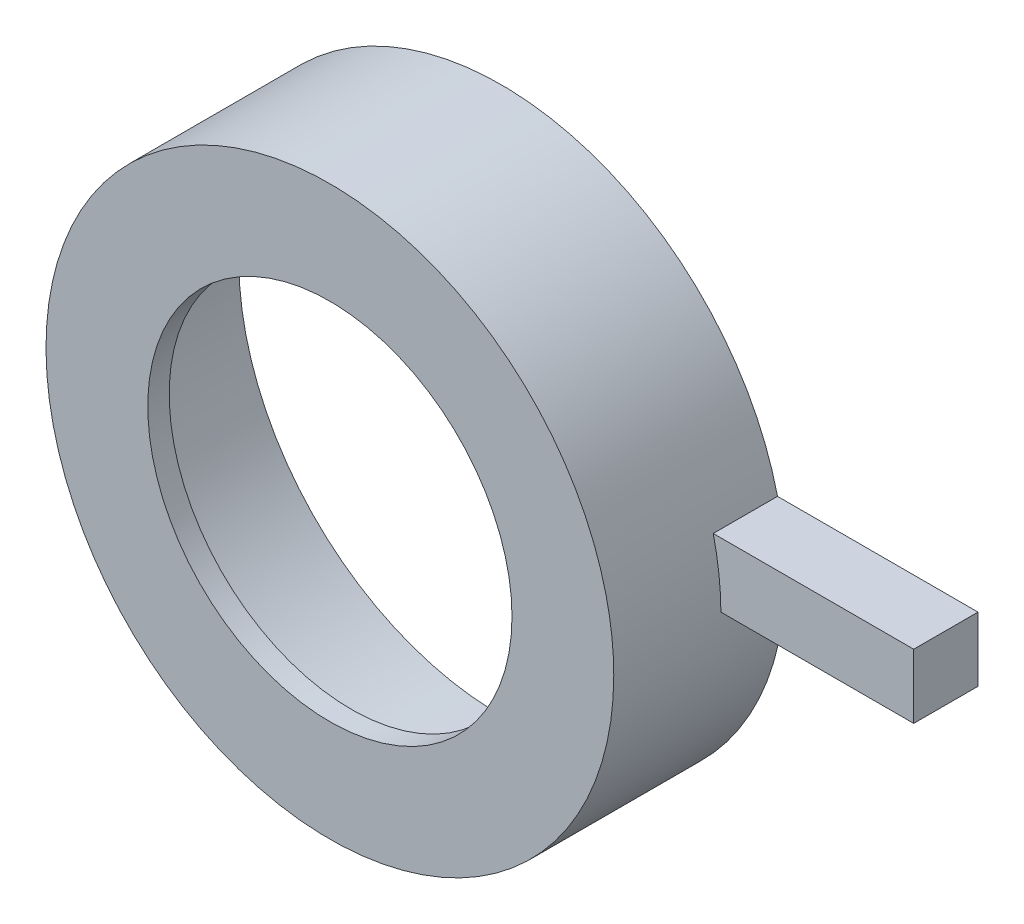
from build123d import *

# Parameters (mm, degrees)
SKETCH_1_R      = 13.25
SKETCH_1_R_2    = 12.25
EXTRUDE_1_DEPTH = 7
SKETCH_2_R      = 13.25
SKETCH_2_R_2    = 8.5
EXTRUDE_2_DEPTH = 1
SKETCH_3_W      = 10
SKETCH_3_H      = 3
EXTRUDE_3_DEPTH = 3


with BuildPart() as part:
    # ｽｹｯﾁ1 → ﾎﾞｽ - 押し出し1 (new body)
    with BuildSketch(Plane.XY):
        Circle(SKETCH_1_R)
        Circle(SKETCH_1_R_2, mode=Mode.SUBTRACT)
    extrude(amount=EXTRUDE_1_DEPTH)

    # ｽｹｯﾁ2 → ﾎﾞｽ - 押し出し2 (add)
    with BuildSketch(Plane.XY.offset(7)):
        Circle(SKETCH_2_R)
        Circle(SKETCH_2_R_2, mode=Mode.SUBTRACT)
    extrude(amount=EXTRUDE_2_DEPTH)

    # ｽｹｯﾁ3 → ﾎﾞｽ - 押し出し3 (add)
    with BuildSketch(Plane.XY):
        with Locations((17.25, 1.556870996)):
            Rectangle(SKETCH_3_W, SKETCH_3_H)
    extrude(amount=EXTRUDE_3_DEPTH)


solid = part.part
